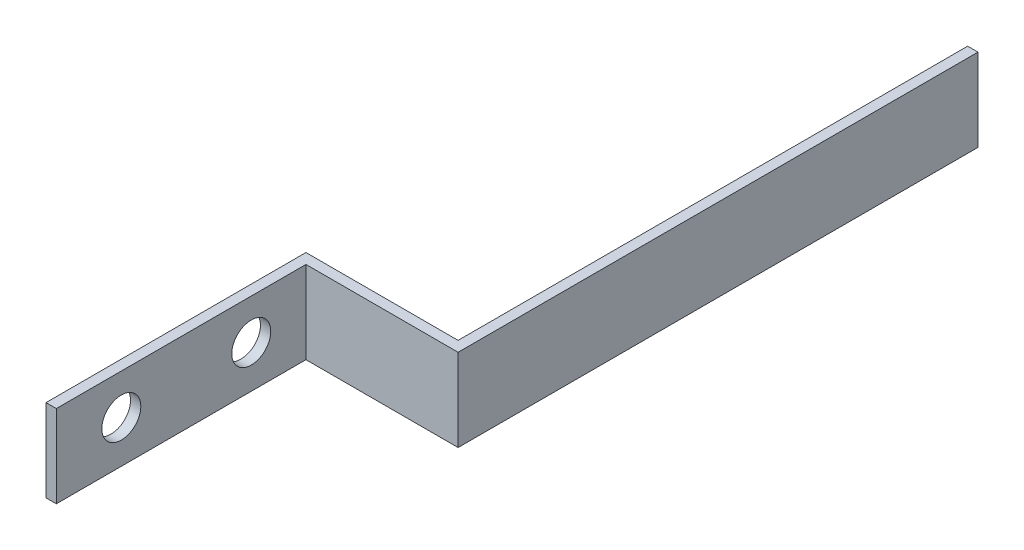
from build123d import *

# Parameters (mm, degrees)
BOSS_EXTRUDE1_DEPTH = 25.4
SKETCH2_R           = 6
CUT_EXTRUDE1_DEPTH  = 25.4


with BuildPart() as part:
    # Sketch1 → Boss-Extrude1 (new body)
    with BuildSketch(Plane(origin=(0, 0, 0), x_dir=(1, 0, 0), z_dir=(0, 1, 0))):
        Polygon((0, 0), (0, 80), (46.825, 80), (46.825, 236.825), (50, 236.825), (50, 76.825), (3.175, 76.825), (3.175, 0), align=None)
    extrude(amount=BOSS_EXTRUDE1_DEPTH)

    # Sketch2 → Cut-Extrude1 (cut)
    with BuildSketch(Plane(origin=(3.175, 0, 0), x_dir=(0, 0, -1), z_dir=(1, 0, 0))):
        with Locations((60, 13)):
            Circle(SKETCH2_R)
        with Locations((20, 13)):
            Circle(SKETCH2_R)
    extrude(amount=-CUT_EXTRUDE1_DEPTH, mode=Mode.SUBTRACT)


solid = part.part
